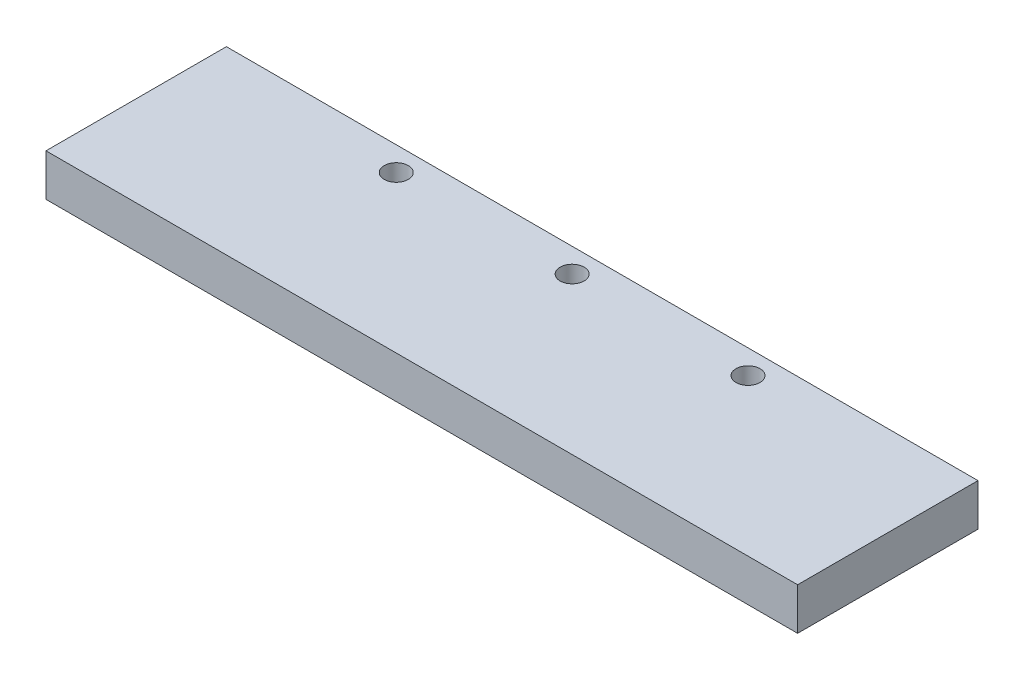
from build123d import *

# Parameters (mm, degrees)
SKETCH1_W           = 125
SKETCH1_H           = 30
BOSS_EXTRUDE1_DEPTH = 7
SKETCH2_R           = 2
CUT_EXTRUDE1_DEPTH  = 10


with BuildPart() as part:
    # Sketch1 → Boss-Extrude1 (new body)
    with BuildSketch(Plane(origin=(0, 0, 0), x_dir=(1, 0, 0), z_dir=(0, 1, 0))):
        with Locations((-40.010460251, 50.167364017)):
            Rectangle(SKETCH1_W, SKETCH1_H)
    extrude(amount=BOSS_EXTRUDE1_DEPTH)

    # Sketch2 → Cut-Extrude1 (cut)
    with BuildSketch(Plane.XZ):
        with Locations((-70.260460251, -61.167364017)):
            Circle(SKETCH2_R)
        with Locations((-41.010460251, -61.167364017)):
            Circle(SKETCH2_R)
        with Locations((-11.760460251, -61.167364017)):
            Circle(SKETCH2_R)
    extrude(amount=-CUT_EXTRUDE1_DEPTH, mode=Mode.SUBTRACT)


solid = part.part
